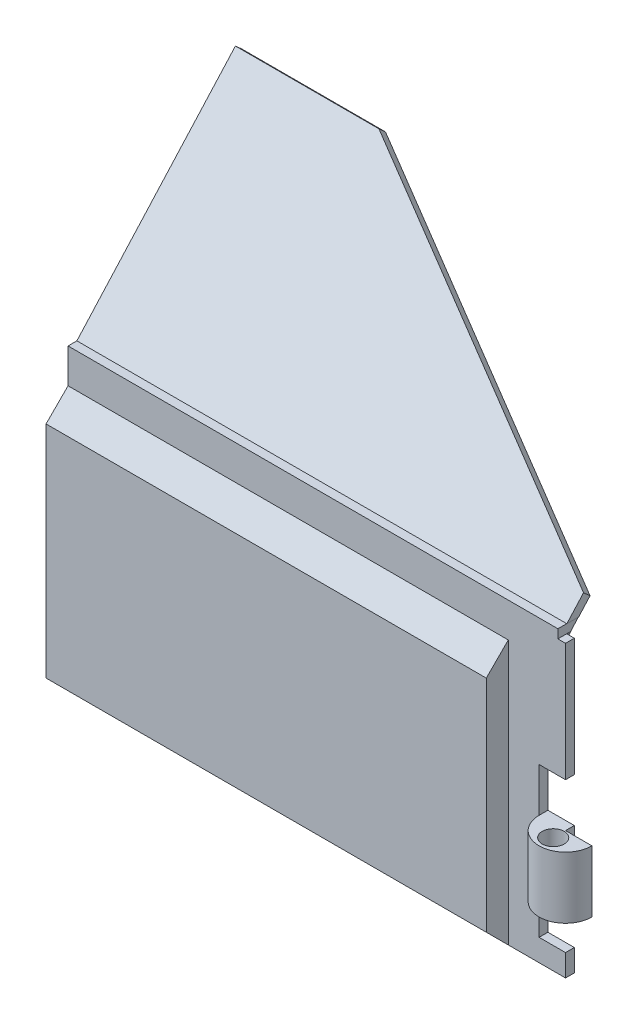
from build123d import *

# Parameters (mm, degrees)
BOSS_EXTRUDE1_DEPTH = 1
BOSS_EXTRUDE2_DEPTH = 7
SKETCH3_R           = 1.25
CUT_EXTRUDE1_DEPTH  = 7
BOSS_EXTRUDE3_DEPTH = 50
BOSS_EXTRUDE4_DEPTH = 1
SKETCH6_W           = 55.65
SKETCH6_H           = 1
BOSS_EXTRUDE5_DEPTH = 0.441482
CUT_EXTRUDE2_REACH  = 21.75
SKETCH7_W           = 0.87
SKETCH7_H           = 1


with BuildPart() as part:
    # Sketch1 → Boss-Extrude1 (new body)
    with BuildSketch(Plane.XY):
        Polygon((-28.25, -16.96), (-28.25, 16.96), (28.25, 16.96), (28.25, 2.54), (25.25, 2.54), (25.25, -2.46), (28.25, -2.46), (28.25, -9.46), (25.25, -9.46), (25.25, -14.46), (28.25, -14.46), (28.25, -16.96), align=None)
    extrude(amount=BOSS_EXTRUDE1_DEPTH)

    # Sketch2 → Boss-Extrude2 (add)
    with BuildSketch(Plane.XZ.offset(9.46)):
        with BuildLine():
            Line((28.25, 1), (31.25, 1))
            ThreePointArc((31.25, 1), (28.25, 4), (25.25, 1))
            Line((25.25, 1), (28.25, 1))
        make_face()
    extrude(amount=-BOSS_EXTRUDE2_DEPTH)

    # Sketch3 → Cut-Extrude1 (cut)
    with BuildSketch(Plane(origin=(0, -2.46, 0), x_dir=(1, 0, 0), z_dir=(0, 1, 0))):
        with Locations((28.25, -2.4)):
            Circle(SKETCH3_R)
    extrude(amount=-CUT_EXTRUDE1_DEPTH, mode=Mode.SUBTRACT)

    # Sketch4 → Boss-Extrude3 (add)
    with BuildSketch(Plane.ZY.offset(28.25)):
        Polygon((1, 13.04), (3.5, 10.54), (3.5, -14.46), (1, -16.96), align=None)
    extrude(amount=-BOSS_EXTRUDE3_DEPTH)



with BuildPart() as body_2:
    # Sketch5 → Boss-Extrude4 (new body)
    with BuildSketch(Plane(origin=(0, 7.593598631, 8.433545673), x_dir=(-1, 0, 0), z_dir=(0, 0.669130606, 0.743144825))):
        Polygon((28.25, -11.934605634), (28.25, -39.514605634), (11.95, -39.514605634), (-27.4, -15.434605634), (-27.4, -11.934605634), align=None)
    extrude(amount=-BOSS_EXTRUDE4_DEPTH)


with BuildPart() as part_1:
    add(part.part)

    add(body_2.part)  # Boss-Extrude5 merges body 2
    # Sketch6 → Boss-Extrude5 (add)
    with BuildSketch(Plane(origin=(0, 8.869140421, -7.985809904), x_dir=(1, 0, 0), z_dir=(0, -0.743144825, 0.669130606))):
        with Locations((-0.425, 10.848455084)):
            Rectangle(SKETCH6_W, SKETCH6_H)
    extrude(amount=BOSS_EXTRUDE5_DEPTH)

    # Cut-Extrude2: up to this face of the body (flat: up to its plane)
    cut_extrude2_end = Plane(part_1.part.faces().sort_by_distance((-6.843835743, 23.936811471, -7.627581995))[0])
    # Sketch7 → Cut-Extrude2 (cut, up to the picked face)
    with BuildSketch(Plane.XY.offset(1), mode=Mode.PRIVATE) as cut_extrude2_sk1:
        with Locations((27.815, 16.46)):
            Rectangle(SKETCH7_W, SKETCH7_H)
    cut_extrude2_tool1 = split(extrude(cut_extrude2_sk1.sketch, amount=-CUT_EXTRUDE2_REACH, mode=Mode.PRIVATE), bisect_by=cut_extrude2_end, keep=Keep.BOTH, mode=Mode.PRIVATE)
    add(cut_extrude2_tool1.solids().sort_by_distance((27.815, 16.46, 1))[0], mode=Mode.SUBTRACT)


solid = part_1.part
